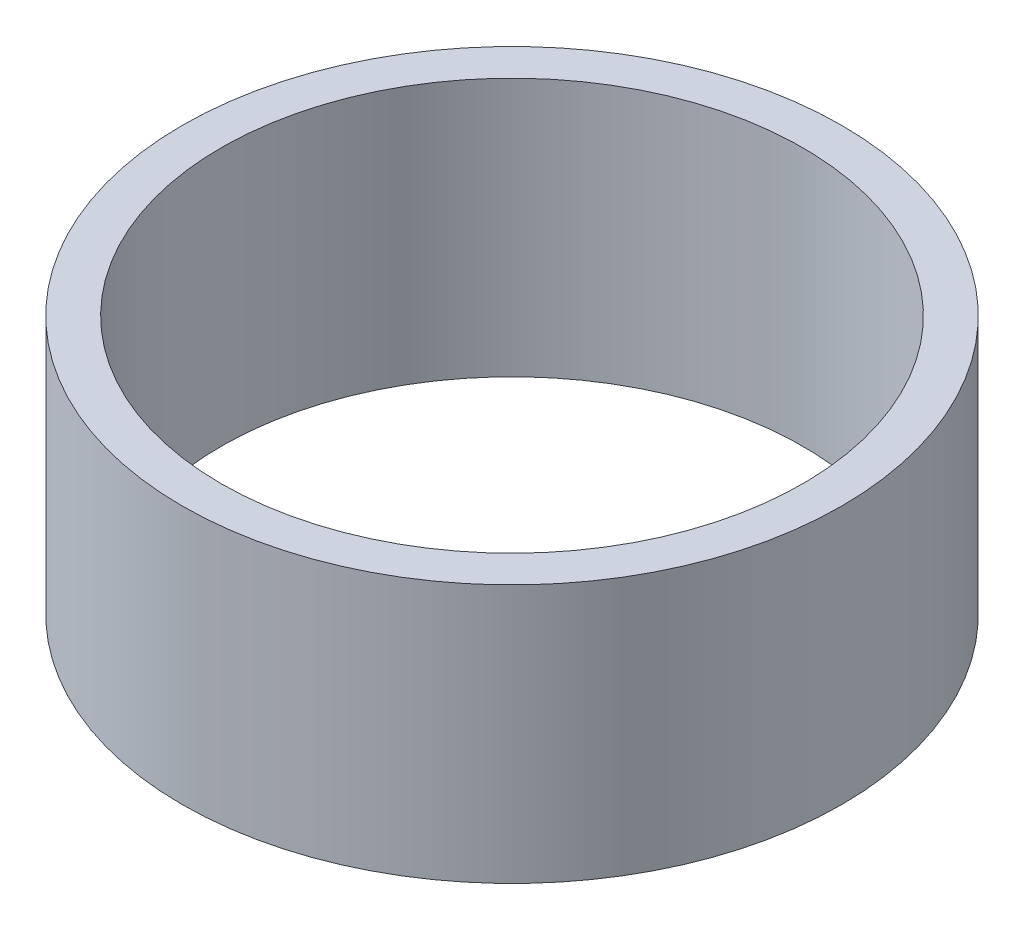
from build123d import *

# Parameters (mm, degrees)
SKETCH_1_R      = 25.5
SKETCH_1_R_2    = 22.5
EXTRUDE_1_DEPTH = 20


with BuildPart() as part:
    # 草图1 → 拉伸-薄壁1 (new body)
    with BuildSketch(Plane(origin=(0, 0, 0), x_dir=(1, 0, 0), z_dir=(0, 1, 0))):
        Circle(SKETCH_1_R)
        Circle(SKETCH_1_R_2, mode=Mode.SUBTRACT)
    extrude(amount=EXTRUDE_1_DEPTH)


solid = part.part
